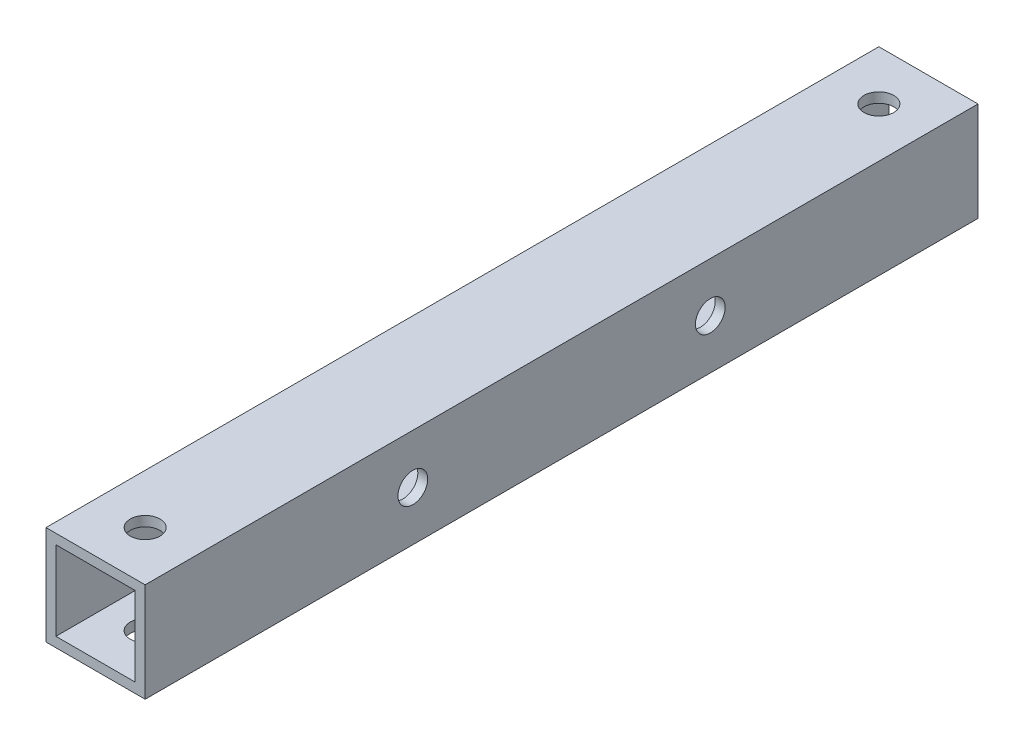
from build123d import *

# Parameters (mm, degrees)
SKETCH_1_W          = 10
SKETCH_1_H          = 10
SKETCH_1_W_2        = 8
SKETCH_1_H_2        = 8
EXTRUDE_1_DEPTH     = 84
SKETCH_2_R          = 1.5
CUT_EXTRUDE_1_DEPTH = 11
SKETCH_3_R          = 1.5
CUT_EXTRUDE_2_DEPTH = 10


with BuildPart() as part:
    # 草图1 → 拉伸-薄壁1 (new body)
    with BuildSketch(Plane.XY):
        Rectangle(SKETCH_1_W, SKETCH_1_H)
        Rectangle(SKETCH_1_W_2, SKETCH_1_H_2, mode=Mode.SUBTRACT)
    extrude(amount=EXTRUDE_1_DEPTH)

    # 草图2 → 切除-拉伸1 (cut, through all)
    with BuildSketch(Plane(origin=(5, 0, 0), x_dir=(0, 0, -1), z_dir=(1, 0, 0))):
        with Locations((-57, 0)):
            Circle(SKETCH_2_R)
        with Locations((-27, 0)):
            Circle(SKETCH_2_R)
    extrude(amount=-CUT_EXTRUDE_1_DEPTH, mode=Mode.SUBTRACT)

    # 草图3 → 切除-拉伸2 (cut)
    with BuildSketch(Plane(origin=(0, 5, 0), x_dir=(1, 0, 0), z_dir=(0, 1, 0))):
        with Locations((0, -5)):
            Circle(SKETCH_3_R)
        with Locations((0, -79)):
            Circle(SKETCH_3_R)
    extrude(amount=-CUT_EXTRUDE_2_DEPTH, mode=Mode.SUBTRACT)


solid = part.part
